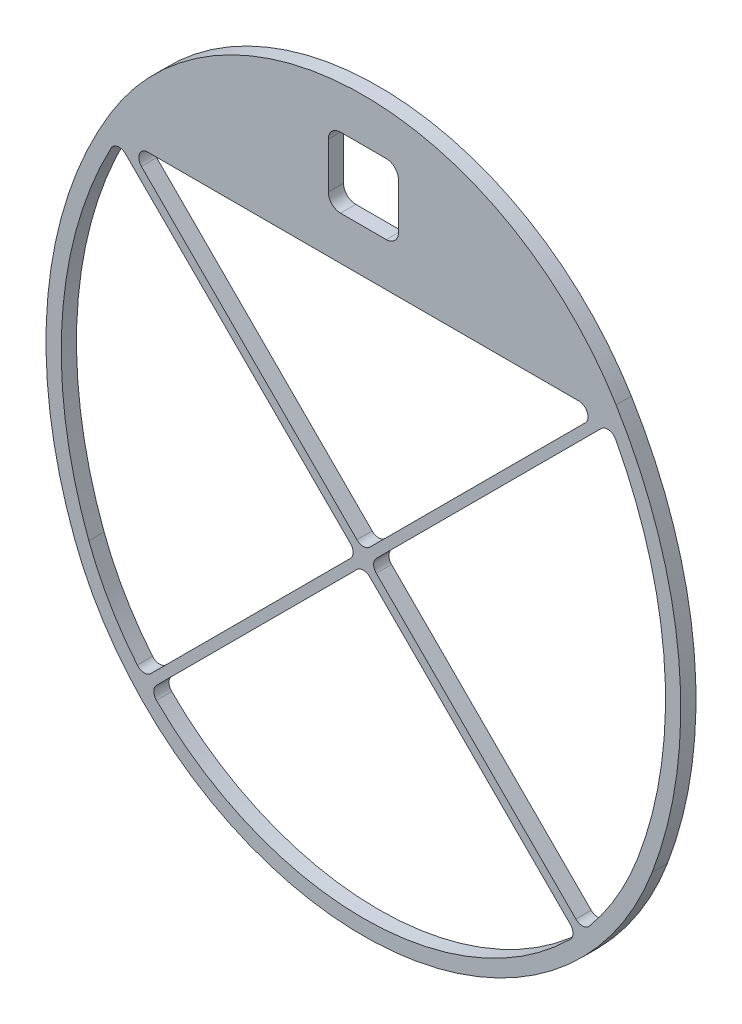
from build123d import *

# Parameters (mm, degrees)
BOSS_EXTRUDE1_DEPTH = 6.35
CUT_EXTRUDE1_REACH  = 8.35
SKETCH2_W           = 29.21
SKETCH2_H           = 29.21
FILLET1_R           = 5.08
BOSS_EXTRUDE2_DEPTH = 6.35
FILLET2_R           = 3.81


with BuildPart() as part:
    # Sketch1 → Boss-Extrude1 (new body)
    with BuildSketch(Plane.XY):
        with BuildLine():
            ThreePointArc((-105.206508748, 158.75), (-131.338700922, 79.990592372), (-120.239774453, -2.245346177))
            ThreePointArc((-120.239774453, -2.245346177), (0, -85.336489431), (120.239774453, -2.245346177))
            ThreePointArc((120.239774453, -2.245346177), (131.338700922, 79.990592372), (105.206508748, 158.75))
            ThreePointArc((105.206508748, 158.75), (0, 217.817133941), (-105.206508748, 158.75))
        make_face()
        with BuildLine():
            Line((-101.6, 152.4), (101.6, 152.4))
            ThreePointArc((101.6, 152.4), (125.172151144, 77.635179262), (114.3, 0))
            ThreePointArc((114.3, 0), (0, -78.986489431), (-114.3, 0))
            ThreePointArc((-114.3, 0), (-125.172151144, 77.635179262), (-101.6, 152.4))
        make_face(mode=Mode.SUBTRACT)
    extrude(amount=BOSS_EXTRUDE1_DEPTH)

    # Sketch2 → Cut-Extrude1 (cut, up to next)
    with BuildSketch(Plane.XY.offset(6.35), mode=Mode.PRIVATE) as cut_extrude1_sk1:
        with Locations((0, 185.10856697)):
            Rectangle(SKETCH2_W, SKETCH2_H)
    cut_extrude1_tool1 = extrude(cut_extrude1_sk1.sketch, amount=-CUT_EXTRUDE1_REACH, mode=Mode.PRIVATE) & part.part
    add(cut_extrude1_tool1.solids().sort_by_distance((0, 185.108567, 6.35))[0], mode=Mode.SUBTRACT)

    # Fillet1
    fillet1_edges = [part.edges().sort_by_distance(p)[0] for p in [
        (14.605, 199.71356697, 3.175),
        (14.605, 170.50356697, 3.175),
        (-14.605, 170.50356697, 3.175),
        (-14.605, 199.71356697, 3.175),
    ]]
    fillet(fillet1_edges, radius=FILLET1_R)

    # Sketch3 → Boss-Extrude2 (add)
    with BuildSketch(Plane.XY.offset(6.35)):
        Polygon((-100.252961582, 153.747038418), (-102.947038418, 151.052961582), (-2.694076836, 50.8), (-93.720570633, -40.226493797), (-91.026493797, -42.920570633), (0, 48.105923164), (91.026493797, -42.920570633), (93.720570633, -40.226493797), (2.694076836, 50.8), (102.947038418, 151.052961582), (100.252961582, 153.747038418), (0, 53.494076836), align=None)
    extrude(amount=-BOSS_EXTRUDE2_DEPTH)

    # Fillet2
    fillet2_edges = [part.edges().sort_by_distance(p)[0] for p in [
        (102.584006308, 150.689929472, 3.175),
        (98.905923164, 152.4, 3.175),
        (-88.818700326, -40.712777162, 3.175),
        (-91.394282222, -37.900205386, 3.175),
        (0, 53.494076836, 3.175),
        (-102.584006308, 150.689929472, 3.175),
        (-98.905923164, 152.4, 3.175),
        (0, 48.105923164, 3.175),
        (88.818700326, -40.712777162, 3.175),
        (91.394282222, -37.900205386, 3.175),
        (2.694076836, 50.8, 3.175),
        (-2.694076836, 50.8, 3.175),
    ]]
    fillet(fillet2_edges, radius=FILLET2_R)


solid = part.part
